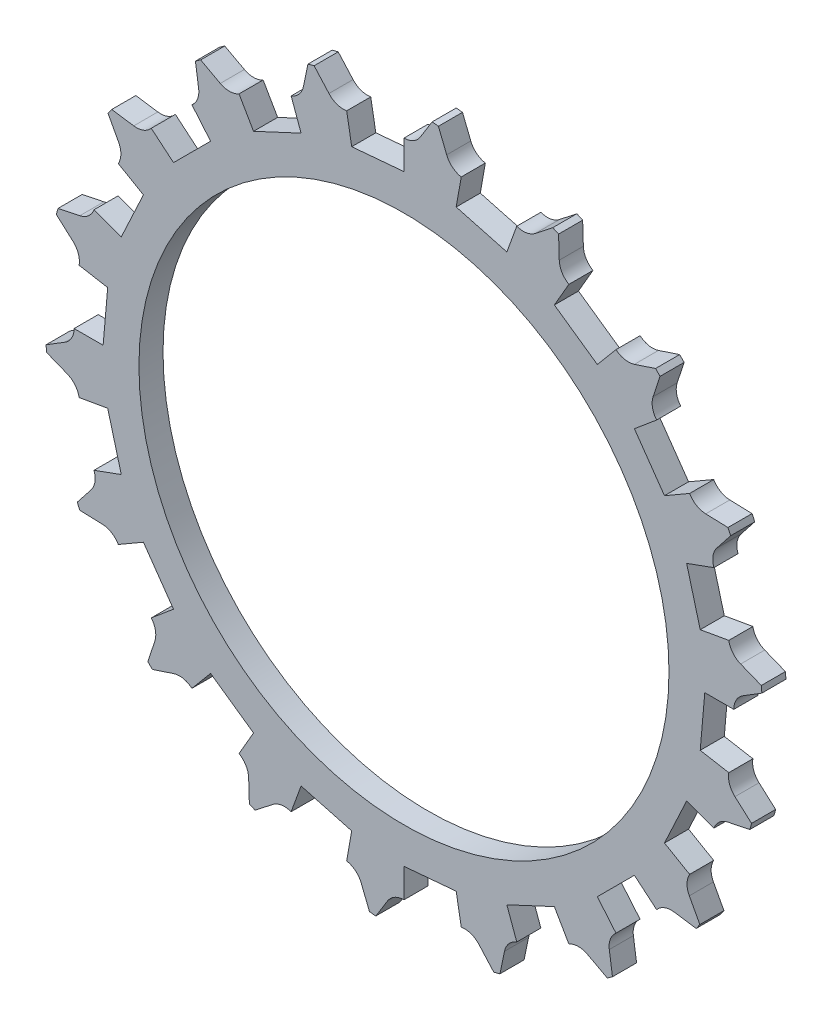
from build123d import *

# Parameters (mm, degrees)
BOSS_EXTRUDE1_DEPTH                 = 5
SKETCH2_R                           = 12.5
BOSS_EXTRUDE2_DEPTH                 = 40
CUT_EXTRUDE2_DEPTH                  = 10
SKETCH9_R                           = 100
SKETCH9_R_2                         = 74.5
CUT_EXTRUDE5_DEPTH                  = 10
FILLET1_R                           = 30
SKETCH3_R                           = 5
CUT_EXTRUDE1_DEPTH                  = 46
F_1_0MM_DOWEL_HOLE1_D               = 2.8
F_1_0MM_DOWEL_HOLE1_DEPTH           = 33.158795133
F_1_0MM_DOWEL_HOLE1_TIP             = 0.841204867
F_1_0MM_DOWEL_HOLE1_ON_FACE_2_D     = 2.8
F_1_0MM_DOWEL_HOLE1_ON_FACE_2_DEPTH = 33.158795133
F_1_0MM_DOWEL_HOLE1_ON_FACE_2_TIP   = 0.841204867
CIRPATTERN1_COUNT                   = 18
SKETCH6_W                           = 154.176776301
SKETCH6_H                           = 45.916506966
CUT_EXTRUDE3_DEPTH                  = 75.271304161
CUT_EXTRUDE3_DEPTH_BACK             = 75.271304161
CUT_EXTRUDE4_DEPTH                  = 1
CUT_EXTRUDE4_DEPTH_BACK             = 6
SKETCH10_R                          = 55
CUT_EXTRUDE6_DEPTH                  = 10


with BuildPart() as part:
    # Sketch1 → Boss-Extrude1 (new body)
    with BuildSketch(Plane.XY):
        with BuildLine():
            ThreePointArc((3.400646872, 70.34391338), (0, 68.45), (-3.400646872, 70.34391338))
            Line((-3.400646872, 70.34391338), (-6.085453124, 74.679004775))
            ThreePointArc((-6.085453124, 74.679004775), (-6.554111855, 74.913841296), (-6.974871672, 74.601190735))
            Line((-6.974871672, 74.601190735), (-8.866108963, 69.865747406))
            ThreePointArc((-8.866108963, 69.865747406), (-11.886217761, 67.410090694), (-15.564075773, 68.684715142))
            Line((-15.564075773, 68.684715142), (-18.960874506, 72.487735044))
            ThreePointArc((-18.960874506, 72.487735044), (-19.463192192, 72.637622137), (-19.823268522, 72.256657264))
            Line((-19.823268522, 72.256657264), (-20.863472565, 67.264746051))
            ThreePointArc((-20.863472565, 67.264746051), (-23.411278811, 64.321959893), (-27.254598108, 64.93856659))
            Line((-27.254598108, 64.93856659), (-31.260179312, 68.093962165))
            ThreePointArc((-31.260179312, 68.093962165), (-31.780893283, 68.154345585), (-32.069345388, 67.716641827))
            Line((-32.069345388, 67.716641827), (-32.226910109, 62.619939425))
            ThreePointArc((-32.226910109, 62.619939425), (-34.225, 59.279438889), (-38.117003271, 59.219292553))
            Line((-38.117003271, 59.219292553), (-42.609659387, 61.631188702))
            ThreePointArc((-42.609659387, 61.631188702), (-43.132948014, 61.600233731), (-43.341011423, 61.119090493))
            Line((-43.341011423, 61.119090493), (-42.611149298, 56.072457626))
            ThreePointArc((-42.611149298, 56.072457626), (-43.998811883, 52.435742131), (-47.821242577, 51.700670278))
            Line((-47.821242577, 51.700670278), (-52.664466523, 53.295782758))
            ThreePointArc((-52.664466523, 53.295782758), (-53.174429945, 53.174429945), (-53.295782758, 52.664466523))
            Line((-53.295782758, 52.664466523), (-51.700670278, 47.821242577))
            ThreePointArc((-51.700670278, 47.821242577), (-52.435742131, 43.998811883), (-56.072457626, 42.611149298))
            Line((-56.072457626, 42.611149298), (-61.119090493, 43.341011423))
            ThreePointArc((-61.119090493, 43.341011423), (-61.600233731, 43.132948014), (-61.631188702, 42.609659387))
            Line((-61.631188702, 42.609659387), (-59.219292553, 38.117003271))
            ThreePointArc((-59.219292553, 38.117003271), (-59.279438889, 34.225), (-62.619939425, 32.226910109))
            Line((-62.619939425, 32.226910109), (-67.716641827, 32.069345388))
            ThreePointArc((-67.716641827, 32.069345388), (-68.154345585, 31.780893283), (-68.093962165, 31.260179312))
            Line((-68.093962165, 31.260179312), (-64.93856659, 27.254598108))
            ThreePointArc((-64.93856659, 27.254598108), (-64.321959893, 23.411278811), (-67.264746051, 20.863472565))
            Line((-67.264746051, 20.863472565), (-72.256657264, 19.823268522))
            ThreePointArc((-72.256657264, 19.823268522), (-72.637622137, 19.463192192), (-72.487735044, 18.960874506))
            Line((-72.487735044, 18.960874506), (-68.684715142, 15.564075773))
            ThreePointArc((-68.684715142, 15.564075773), (-67.410090694, 11.886217761), (-69.865747406, 8.866108963))
            Line((-69.865747406, 8.866108963), (-74.601190735, 6.974871672))
            ThreePointArc((-74.601190735, 6.974871672), (-74.913841296, 6.554111855), (-74.679004775, 6.085453124))
            Line((-74.679004775, 6.085453124), (-70.34391338, 3.400646872))
            ThreePointArc((-70.34391338, 3.400646872), (-68.45, 0), (-70.34391338, -3.400646872))
            Line((-70.34391338, -3.400646872), (-74.679004775, -6.085453124))
            ThreePointArc((-74.679004775, -6.085453124), (-74.913841296, -6.554111855), (-74.601190735, -6.974871672))
            Line((-74.601190735, -6.974871672), (-69.865747406, -8.866108963))
            ThreePointArc((-69.865747406, -8.866108963), (-67.410090694, -11.886217761), (-68.684715142, -15.564075773))
            Line((-68.684715142, -15.564075773), (-72.487735044, -18.960874506))
            ThreePointArc((-72.487735044, -18.960874506), (-72.637622137, -19.463192192), (-72.256657264, -19.823268522))
            Line((-72.256657264, -19.823268522), (-67.264746051, -20.863472565))
            ThreePointArc((-67.264746051, -20.863472565), (-64.321959893, -23.411278811), (-64.93856659, -27.254598108))
            Line((-64.93856659, -27.254598108), (-68.093962165, -31.260179312))
            ThreePointArc((-68.093962165, -31.260179312), (-68.154345585, -31.780893283), (-67.716641827, -32.069345388))
            Line((-67.716641827, -32.069345388), (-62.619939425, -32.226910109))
            ThreePointArc((-62.619939425, -32.226910109), (-59.279438889, -34.225), (-59.219292553, -38.117003271))
            Line((-59.219292553, -38.117003271), (-61.631188702, -42.609659387))
            ThreePointArc((-61.631188702, -42.609659387), (-61.600233731, -43.132948014), (-61.119090493, -43.341011423))
            Line((-61.119090493, -43.341011423), (-56.072457626, -42.611149298))
            ThreePointArc((-56.072457626, -42.611149298), (-52.435742131, -43.998811883), (-51.700670278, -47.821242577))
            Line((-51.700670278, -47.821242577), (-53.295782758, -52.664466523))
            ThreePointArc((-53.295782758, -52.664466523), (-53.174429945, -53.174429945), (-52.664466523, -53.295782758))
            Line((-52.664466523, -53.295782758), (-47.821242577, -51.700670278))
            ThreePointArc((-47.821242577, -51.700670278), (-43.998811883, -52.435742131), (-42.611149298, -56.072457626))
            Line((-42.611149298, -56.072457626), (-43.341011423, -61.119090493))
            ThreePointArc((-43.341011423, -61.119090493), (-43.132948014, -61.600233731), (-42.609659387, -61.631188702))
            Line((-42.609659387, -61.631188702), (-38.117003271, -59.219292553))
            ThreePointArc((-38.117003271, -59.219292553), (-34.225, -59.279438889), (-32.226910109, -62.619939425))
            Line((-32.226910109, -62.619939425), (-32.069345388, -67.716641827))
            ThreePointArc((-32.069345388, -67.716641827), (-31.780893283, -68.154345585), (-31.260179312, -68.093962165))
            Line((-31.260179312, -68.093962165), (-27.254598108, -64.93856659))
            ThreePointArc((-27.254598108, -64.93856659), (-23.411278811, -64.321959893), (-20.863472565, -67.264746051))
            Line((-20.863472565, -67.264746051), (-19.823268522, -72.256657264))
            ThreePointArc((-19.823268522, -72.256657264), (-19.463192192, -72.637622137), (-18.960874506, -72.487735044))
            Line((-18.960874506, -72.487735044), (-15.564075773, -68.684715142))
            ThreePointArc((-15.564075773, -68.684715142), (-11.886217761, -67.410090694), (-8.866108963, -69.865747406))
            Line((-8.866108963, -69.865747406), (-6.974871672, -74.601190735))
            ThreePointArc((-6.974871672, -74.601190735), (-6.554111855, -74.913841296), (-6.085453124, -74.679004775))
            Line((-6.085453124, -74.679004775), (-3.400646872, -70.34391338))
            ThreePointArc((-3.400646872, -70.34391338), (0, -68.45), (3.400646872, -70.34391338))
            Line((3.400646872, -70.34391338), (6.085453124, -74.679004775))
            ThreePointArc((6.085453124, -74.679004775), (6.554111855, -74.913841296), (6.974871672, -74.601190735))
            Line((6.974871672, -74.601190735), (8.866108963, -69.865747406))
            ThreePointArc((8.866108963, -69.865747406), (11.886217761, -67.410090694), (15.564075773, -68.684715142))
            Line((15.564075773, -68.684715142), (18.960874506, -72.487735044))
            ThreePointArc((18.960874506, -72.487735044), (19.463192192, -72.637622137), (19.823268522, -72.256657264))
            Line((19.823268522, -72.256657264), (20.863472565, -67.264746051))
            ThreePointArc((20.863472565, -67.264746051), (23.411278811, -64.321959893), (27.254598108, -64.93856659))
            Line((27.254598108, -64.93856659), (31.260179312, -68.093962165))
            ThreePointArc((31.260179312, -68.093962165), (31.780893283, -68.154345585), (32.069345388, -67.716641827))
            Line((32.069345388, -67.716641827), (32.226910109, -62.619939425))
            ThreePointArc((32.226910109, -62.619939425), (34.225, -59.279438889), (38.117003271, -59.219292553))
            Line((38.117003271, -59.219292553), (42.609659387, -61.631188702))
            ThreePointArc((42.609659387, -61.631188702), (43.132948014, -61.600233731), (43.341011423, -61.119090493))
            Line((43.341011423, -61.119090493), (42.611149298, -56.072457626))
            ThreePointArc((42.611149298, -56.072457626), (43.998811883, -52.435742131), (47.821242577, -51.700670278))
            Line((47.821242577, -51.700670278), (52.664466523, -53.295782758))
            ThreePointArc((52.664466523, -53.295782758), (53.174429945, -53.174429945), (53.295782758, -52.664466523))
            Line((53.295782758, -52.664466523), (51.700670278, -47.821242577))
            ThreePointArc((51.700670278, -47.821242577), (52.435742131, -43.998811883), (56.072457626, -42.611149298))
            Line((56.072457626, -42.611149298), (61.119090493, -43.341011423))
            ThreePointArc((61.119090493, -43.341011423), (61.600233731, -43.132948014), (61.631188702, -42.609659387))
            Line((61.631188702, -42.609659387), (59.219292553, -38.117003271))
            ThreePointArc((59.219292553, -38.117003271), (59.279438889, -34.225), (62.619939425, -32.226910109))
            Line((62.619939425, -32.226910109), (67.716641827, -32.069345388))
            ThreePointArc((67.716641827, -32.069345388), (68.154345585, -31.780893283), (68.093962165, -31.260179312))
            Line((68.093962165, -31.260179312), (64.93856659, -27.254598108))
            ThreePointArc((64.93856659, -27.254598108), (64.321959893, -23.411278811), (67.264746051, -20.863472565))
            Line((67.264746051, -20.863472565), (72.256657264, -19.823268522))
            ThreePointArc((72.256657264, -19.823268522), (72.637622137, -19.463192192), (72.487735044, -18.960874506))
            Line((72.487735044, -18.960874506), (68.684715142, -15.564075773))
            ThreePointArc((68.684715142, -15.564075773), (67.410090694, -11.886217761), (69.865747406, -8.866108963))
            Line((69.865747406, -8.866108963), (74.601190735, -6.974871672))
            ThreePointArc((74.601190735, -6.974871672), (74.913841296, -6.554111855), (74.679004775, -6.085453124))
            Line((74.679004775, -6.085453124), (70.34391338, -3.400646872))
            ThreePointArc((70.34391338, -3.400646872), (68.45, 0), (70.34391338, 3.400646872))
            Line((70.34391338, 3.400646872), (74.679004775, 6.085453124))
            ThreePointArc((74.679004775, 6.085453124), (74.913841296, 6.554111855), (74.601190735, 6.974871672))
            Line((74.601190735, 6.974871672), (69.865747406, 8.866108963))
            ThreePointArc((69.865747406, 8.866108963), (67.410090694, 11.886217761), (68.684715142, 15.564075773))
            Line((68.684715142, 15.564075773), (72.487735044, 18.960874506))
            ThreePointArc((72.487735044, 18.960874506), (72.637622137, 19.463192192), (72.256657264, 19.823268522))
            Line((72.256657264, 19.823268522), (67.264746051, 20.863472565))
            ThreePointArc((67.264746051, 20.863472565), (64.321959893, 23.411278811), (64.93856659, 27.254598108))
            Line((64.93856659, 27.254598108), (68.093962165, 31.260179312))
            ThreePointArc((68.093962165, 31.260179312), (68.154345585, 31.780893283), (67.716641827, 32.069345388))
            Line((67.716641827, 32.069345388), (62.619939425, 32.226910109))
            ThreePointArc((62.619939425, 32.226910109), (59.279438889, 34.225), (59.219292553, 38.117003271))
            Line((59.219292553, 38.117003271), (61.631188702, 42.609659387))
            ThreePointArc((61.631188702, 42.609659387), (61.600233731, 43.132948014), (61.119090493, 43.341011423))
            Line((61.119090493, 43.341011423), (56.072457626, 42.611149298))
            ThreePointArc((56.072457626, 42.611149298), (52.435742131, 43.998811883), (51.700670278, 47.821242577))
            Line((51.700670278, 47.821242577), (53.295782758, 52.664466523))
            ThreePointArc((53.295782758, 52.664466523), (53.174429945, 53.174429945), (52.664466523, 53.295782758))
            Line((52.664466523, 53.295782758), (47.821242577, 51.700670278))
            ThreePointArc((47.821242577, 51.700670278), (43.998811883, 52.435742131), (42.611149298, 56.072457626))
            Line((42.611149298, 56.072457626), (43.341011423, 61.119090493))
            ThreePointArc((43.341011423, 61.119090493), (43.132948014, 61.600233731), (42.609659387, 61.631188702))
            Line((42.609659387, 61.631188702), (38.117003271, 59.219292553))
            ThreePointArc((38.117003271, 59.219292553), (34.225, 59.279438889), (32.226910109, 62.619939425))
            Line((32.226910109, 62.619939425), (32.069345388, 67.716641827))
            ThreePointArc((32.069345388, 67.716641827), (31.780893283, 68.154345585), (31.260179312, 68.093962165))
            Line((31.260179312, 68.093962165), (27.254598108, 64.93856659))
            ThreePointArc((27.254598108, 64.93856659), (23.411278811, 64.321959893), (20.863472565, 67.264746051))
            Line((20.863472565, 67.264746051), (19.823268522, 72.256657264))
            ThreePointArc((19.823268522, 72.256657264), (19.463192192, 72.637622137), (18.960874506, 72.487735044))
            Line((18.960874506, 72.487735044), (15.564075773, 68.684715142))
            ThreePointArc((15.564075773, 68.684715142), (11.886217761, 67.410090694), (8.866108963, 69.865747406))
            Line((8.866108963, 69.865747406), (6.974871672, 74.601190735))
            ThreePointArc((6.974871672, 74.601190735), (6.554111855, 74.913841296), (6.085453124, 74.679004775))
            Line((6.085453124, 74.679004775), (3.400646872, 70.34391338))
        make_face()
    extrude(amount=BOSS_EXTRUDE1_DEPTH)

    # Sketch2 → Boss-Extrude2 (add)
    with BuildSketch(Plane.XY.offset(5)):
        Circle(SKETCH2_R)
    extrude(amount=BOSS_EXTRUDE2_DEPTH)

    # Sketch5 → Cut-Extrude2 (cut)
    with BuildSketch(Plane(origin=(0, 0, 0), x_dir=(-1, 0, 0), z_dir=(0, 0, -1))):
        with BuildLine():
            ThreePointArc((0, 68.45), (5.710404715, 65.270224566), (11.886217761, 67.410090694))
            Line((11.886217761, 67.410090694), (10.840348848, 61.478673342))
            Line((10.840348848, 61.478673342), (0, 62.427080975))
            Line((0, 62.427080975), (0, 68.45))
        make_face()
        with BuildLine():
            Line((0, 68.45), (0.611002974, 75.43379595))
            Line((0.611002974, 75.43379595), (12.497220735, 74.393886643))
            Line((12.497220735, 74.393886643), (11.886217761, 67.410090694))
            ThreePointArc((11.886217761, 67.410090694), (5.710404715, 65.270224566), (0, 68.45))
        make_face()
    cut_extrude2 = extrude(amount=-CUT_EXTRUDE2_DEPTH, mode=Mode.SUBTRACT)

    # Sketch9 → Cut-Extrude5 (cut)
    with BuildSketch(Plane(origin=(0, 0, 0), x_dir=(-1, 0, 0), z_dir=(0, 0, -1))):
        Circle(SKETCH9_R)
        Circle(SKETCH9_R_2, mode=Mode.SUBTRACT)
    extrude(amount=-CUT_EXTRUDE5_DEPTH, mode=Mode.SUBTRACT)

    # Fillet1
    fillet1_edges = [part.edges().sort_by_distance(p)[0] for p in [
        (-12.5, 0, 5),
    ]]
    fillet(fillet1_edges, radius=FILLET1_R)

    # Sketch3 → Cut-Extrude1 (cut, through all)
    with BuildSketch(Plane.XY.offset(45)):
        Circle(SKETCH3_R)
    extrude(amount=-CUT_EXTRUDE1_DEPTH, mode=Mode.SUBTRACT)

    # Ø1.0mm Dowel Hole1
    with Locations(Plane(origin=(-6.81763654, -10.477109907, 42.020116055), x_dir=(-0.838168793, 0.545410923, 0), z_dir=(-0.545410923, -0.838168793, 0))):
        with Locations((0, 0)):
            Hole(F_1_0MM_DOWEL_HOLE1_D / 2, depth=F_1_0MM_DOWEL_HOLE1_DEPTH)
            with Locations((0, 0, -(F_1_0MM_DOWEL_HOLE1_DEPTH + F_1_0MM_DOWEL_HOLE1_TIP / 2))):  # 118° drill point
                Cone(0, F_1_0MM_DOWEL_HOLE1_D / 2, F_1_0MM_DOWEL_HOLE1_TIP, mode=Mode.SUBTRACT)

    # Ø1.0mm Dowel Hole1 on face 2
    with Locations(Plane(origin=(-11.068439798, 5.808583342, 41.658255729), x_dir=(-0.464687004, -0.885475007, 0), z_dir=(-0.885475007, 0.464687004, 0))):
        with Locations((0, 0)):
            Hole(F_1_0MM_DOWEL_HOLE1_ON_FACE_2_D / 2, depth=F_1_0MM_DOWEL_HOLE1_ON_FACE_2_DEPTH)
            with Locations((0, 0, -(F_1_0MM_DOWEL_HOLE1_ON_FACE_2_DEPTH + F_1_0MM_DOWEL_HOLE1_ON_FACE_2_TIP / 2))):  # 118° drill point
                Cone(0, F_1_0MM_DOWEL_HOLE1_ON_FACE_2_D / 2, F_1_0MM_DOWEL_HOLE1_ON_FACE_2_TIP, mode=Mode.SUBTRACT)

    # CirPattern1: Cut-Extrude2 ×18 about axis
    cirpattern1_axis = Axis((0, 0, 0), (0, 0, 1))
    for i in range(1, CIRPATTERN1_COUNT):
        add(cut_extrude2.rotate(cirpattern1_axis, i * 360 / CIRPATTERN1_COUNT), mode=Mode.SUBTRACT)

    # Sketch6 → Cut-Extrude3 (cut, two sides)
    with BuildSketch(Plane(origin=(0, 0, 0), x_dir=(1, 0, 0), z_dir=(0, 1, 0))) as cut_extrude3_sk:
        with Locations((2.817083989, -27.958253483)):
            Rectangle(SKETCH6_W, SKETCH6_H)
    extrude(amount=CUT_EXTRUDE3_DEPTH, mode=Mode.SUBTRACT)
    extrude(cut_extrude3_sk.sketch, amount=-CUT_EXTRUDE3_DEPTH_BACK, mode=Mode.SUBTRACT)

    # Sketch7 → Cut-Extrude4 (cut, two sides)
    with BuildSketch(Plane(origin=(0, 0, 0), x_dir=(-1, 0, 0), z_dir=(0, 0, -1))) as cut_extrude4_sk:
        Polygon((12.6, -7.274613392), (12.6, 7.274613392), (0, 14.549226784), (-12.6, 7.274613392), (-12.6, -7.274613392), (0, -14.549226784), align=None)
    extrude(amount=CUT_EXTRUDE4_DEPTH, mode=Mode.SUBTRACT)
    extrude(cut_extrude4_sk.sketch, amount=-CUT_EXTRUDE4_DEPTH_BACK, mode=Mode.SUBTRACT)

    # Sketch10 → Cut-Extrude6 (cut)
    with BuildSketch(Plane(origin=(0, 0, 0), x_dir=(-1, 0, 0), z_dir=(0, 0, -1))):
        Circle(SKETCH10_R)
    extrude(amount=-CUT_EXTRUDE6_DEPTH, mode=Mode.SUBTRACT)


solid = part.part
